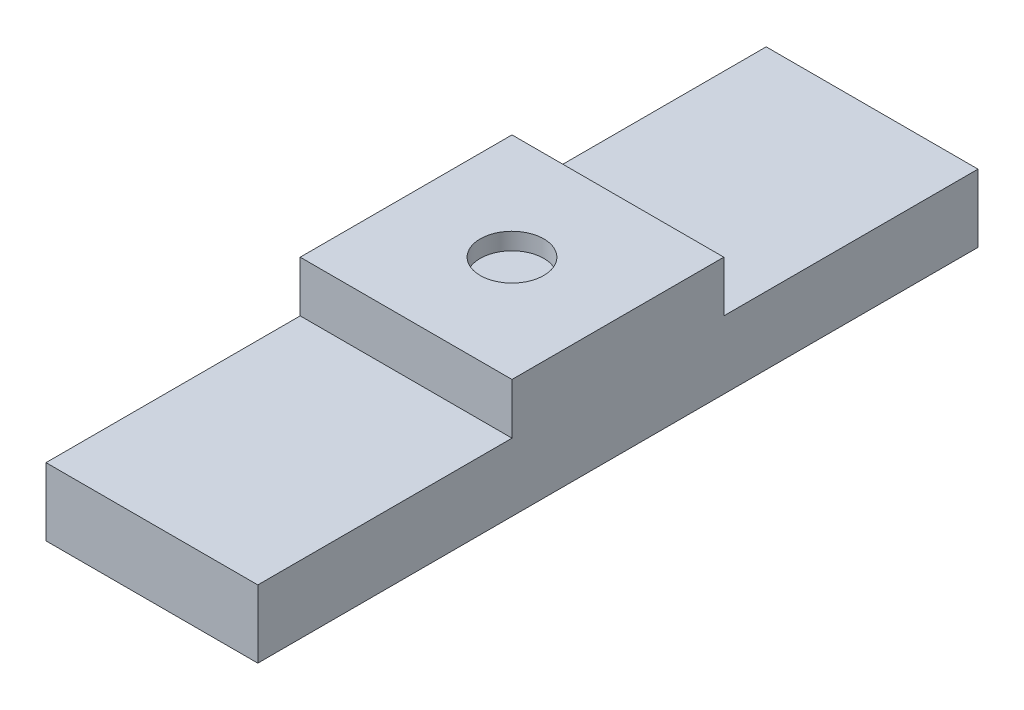
from build123d import *

# Parameters (mm, degrees)
SKETCH1_W           = 2.5
SKETCH1_H           = 8.5
BOSS_EXTRUDE1_DEPTH = 0.8
SKETCH2_W           = 2.5
SKETCH2_H           = 2.5
BOSS_EXTRUDE2_DEPTH = 0.6
SKETCH3_R           = 0.375
CUT_EXTRUDE1_DEPTH  = 0.2


with BuildPart() as part:
    # Sketch1 → Boss-Extrude1 (new body)
    with BuildSketch(Plane(origin=(0, 0, 0), x_dir=(1, 0, 0), z_dir=(0, 1, 0))):
        with Locations((1.25, 4.25)):
            Rectangle(SKETCH1_W, SKETCH1_H)
    extrude(amount=BOSS_EXTRUDE1_DEPTH)

    # Sketch2 → Boss-Extrude2 (add)
    with BuildSketch(Plane(origin=(0, 0.8, 0), x_dir=(1, 0, 0), z_dir=(0, 1, 0))):
        with Locations((1.25, 4.25)):
            Rectangle(SKETCH2_W, SKETCH2_H)
    extrude(amount=BOSS_EXTRUDE2_DEPTH)

    # Sketch3 → Cut-Extrude1 (cut)
    with BuildSketch(Plane(origin=(0, 1.4, 0), x_dir=(1, 0, 0), z_dir=(0, 1, 0))):
        with Locations((1.25, 4.25)):
            Circle(SKETCH3_R)
    extrude(amount=-CUT_EXTRUDE1_DEPTH, mode=Mode.SUBTRACT)


solid = part.part
